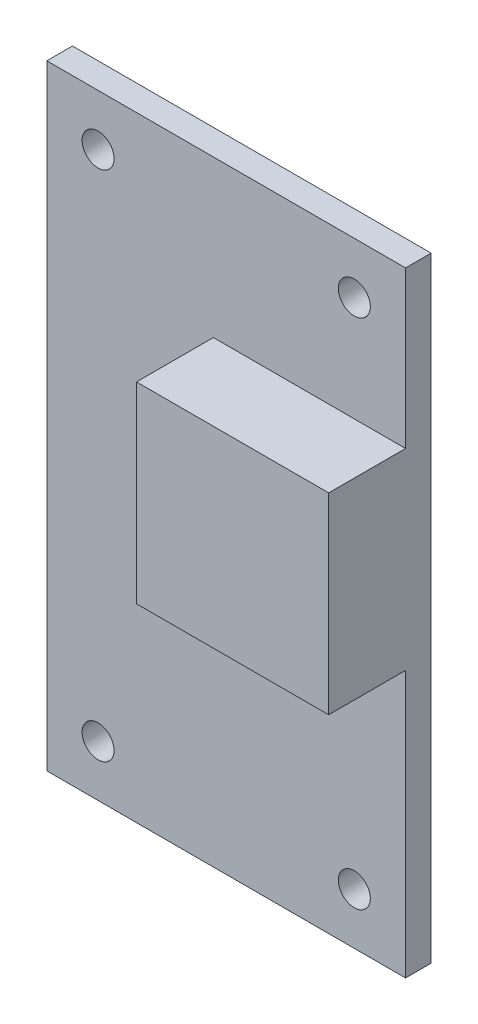
from build123d import *

# Parameters (mm, degrees)
CROQUIS1_W              = 28
CROQUIS1_H              = 48
SALIENTE_EXTRUIR1_DEPTH = 2
CROQUIS2_R              = 1.25
CORTAR_EXTRUIR1_DEPTH   = 3
CROQUIS3_W              = 15
CROQUIS3_H              = 15
SALIENTE_EXTRUIR2_DEPTH = 6


with BuildPart() as part:
    # Croquis1 → Saliente-Extruir1 (new body)
    with BuildSketch(Plane.XY):
        Rectangle(CROQUIS1_W, CROQUIS1_H)
    extrude(amount=SALIENTE_EXTRUIR1_DEPTH)

    # Croquis2 → Cortar-Extruir1 (cut, through all)
    with BuildSketch(Plane.XY.offset(2)):
        with Locations((-10, 20)):
            Circle(CROQUIS2_R)
        with Locations((10, 20)):
            Circle(CROQUIS2_R)
        with Locations((10, -20)):
            Circle(CROQUIS2_R)
        with Locations((-10, -20)):
            Circle(CROQUIS2_R)
    extrude(amount=-CORTAR_EXTRUIR1_DEPTH, mode=Mode.SUBTRACT)

    # Croquis3 → Saliente-Extruir2 (add)
    with BuildSketch(Plane.XY.offset(2)):
        with Locations((6.5, 4.293122568)):
            Rectangle(CROQUIS3_W, CROQUIS3_H)
    extrude(amount=SALIENTE_EXTRUIR2_DEPTH)


solid = part.part
